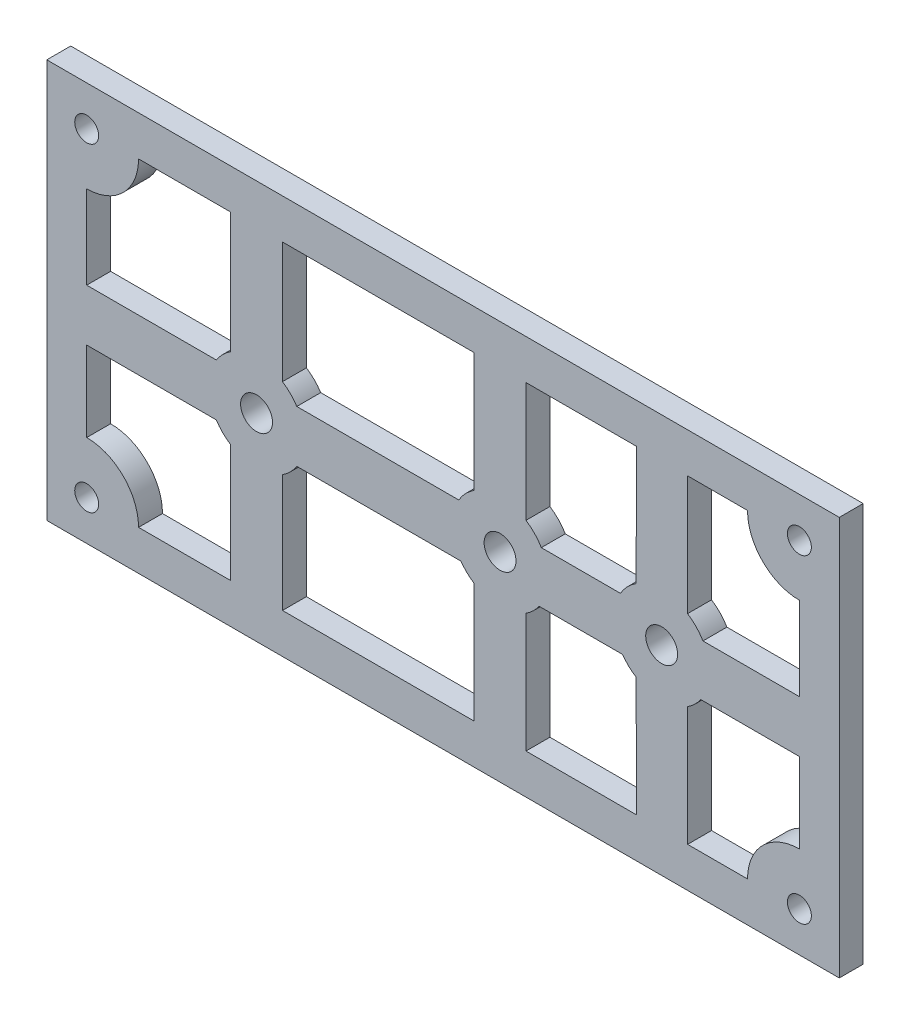
from build123d import *

# Parameters (mm, degrees)
SKETCH1_W               = 115
SKETCH1_H               = 50
BOSS_EXTRUDE1_DEPTH     = 3
CUT_EXTRUDE1_START      = -4
SKETCH2_R               = 1.5
CUT_EXTRUDE1_DEPTH      = 5
SKETCH4_R               = 2
CUT_EXTRUDE2_DEPTH      = 4
SKETCH5_R               = 2
CUT_EXTRUDE3_DEPTH      = 10
SKETCH6_R               = 2
CUT_EXTRUDE4_DEPTH      = 10
SKETCH7_W               = 15.674157042
SKETCH7_H               = 50
CUT_EXTRUDE5_DEPTH      = 10
MIRROR2_START           = -4
MIRROR2_COPY_1_SKETCH_R = 1.5
MIRROR2_COPY_1_DEPTH    = 5
CUT_EXTRUDE6_DEPTH      = 10


with BuildPart() as part:
    # Sketch1 → Boss-Extrude1 (new body)
    with BuildSketch(Plane.XY):
        Rectangle(SKETCH1_W, SKETCH1_H)
    extrude(amount=BOSS_EXTRUDE1_DEPTH)

    # Sketch2 → Cut-Extrude1 (cut)
    with BuildSketch(Plane.XY.offset(3).offset(CUT_EXTRUDE1_START)):
        with Locations((-52.5, 20)):
            Circle(SKETCH2_R)
    cut_extrude1 = extrude(amount=CUT_EXTRUDE1_DEPTH, mode=Mode.SUBTRACT)

    # Sketch4 → Cut-Extrude2 (cut, through all)
    with BuildSketch(Plane.XY.offset(3)):
        with Locations((-31.210457155, -0.20944607)):
            Circle(SKETCH4_R)
    extrude(amount=-CUT_EXTRUDE2_DEPTH, mode=Mode.SUBTRACT)

    # Sketch5 → Cut-Extrude3 (cut)
    with BuildSketch(Plane.XY.offset(3)):
        with Locations((-0.691956257, 0)):
            Circle(SKETCH5_R)
    extrude(amount=-CUT_EXTRUDE3_DEPTH, mode=Mode.SUBTRACT)

    # Sketch6 → Cut-Extrude4 (cut)
    with BuildSketch(Plane.XY.offset(3)):
        with Locations((19.565842958, 0)):
            Circle(SKETCH6_R)
    extrude(amount=-CUT_EXTRUDE4_DEPTH, mode=Mode.SUBTRACT)

    # Sketch7 → Cut-Extrude5 (cut)
    with BuildSketch(Plane.XY.offset(3)):
        with Locations((49.662921479, 0)):
            Rectangle(SKETCH7_W, SKETCH7_H)
    extrude(amount=-CUT_EXTRUDE5_DEPTH, mode=Mode.SUBTRACT)

    # Mirror1: Cut-Extrude1 across plane
    add(cut_extrude1.mirror(Plane.ZY.offset(7.837078521)), mode=Mode.SUBTRACT)

    # Mirror2: Cut-Extrude1 across plane
    add(cut_extrude1.mirror(Plane.ZX), mode=Mode.SUBTRACT)

    # Mirror2 copy 1 sketch → Mirror2 copy 1 (cut)
    with BuildSketch(Plane(origin=(-15.674157042, 0, 3), x_dir=(-1, 0, 0), z_dir=(0, 0, 1)).offset(MIRROR2_START)):
        with Locations((-52.5, 20)):
            Circle(MIRROR2_COPY_1_SKETCH_R)
    extrude(amount=MIRROR2_COPY_1_DEPTH, mode=Mode.SUBTRACT)

    # Sketch8 → Cut-Extrude6 (cut)
    with BuildSketch(Plane.XY.offset(3)):
        with BuildLine():
            ThreePointArc((-52.5, 13.5), (-47.903805922, 15.403805922), (-46, 20))
            Line((-46, 20), (-34.460457155, 20))
            Line((-34.460457155, 20), (-34.460457155, 4.834114181))
            ThreePointArc((-34.460457155, 4.834114181), (-35.453097842, 4.033194618), (-36.254017405, 3.04055393))
            Line((-36.254017405, 3.04055393), (-52.5, 3.04055393))
            Line((-52.5, 3.04055393), (-52.5, 13.5))
        make_face()
        with BuildLine():
            ThreePointArc((-3.941956257, 5.04356025), (-5.020668226, 4.15478672), (-5.864482893, 3.04055393))
            Line((-5.864482893, 3.04055393), (-26.166896904, 3.04055393))
            ThreePointArc((-26.166896904, 3.04055393), (-26.967816468, 4.033194618), (-27.960457155, 4.834114181))
            Line((-27.960457155, 4.834114181), (-27.960457155, 20))
            Line((-27.960457155, 20), (-3.941956257, 20))
            Line((-3.941956257, 20), (-3.941956257, 5.04356025))
        make_face()
        with BuildLine():
            ThreePointArc((4.480570379, 3.04055393), (3.636755712, 4.15478672), (2.558043743, 5.04356025))
            Line((2.558043743, 5.04356025), (2.558043743, 20))
            Line((2.558043743, 20), (16.44194335, 20))
            Line((16.44194335, 20), (16.347771528, 5.063992128))
            ThreePointArc((16.347771528, 5.063992128), (15.250277003, 4.168439815), (14.393316322, 3.04055393))
            Line((14.393316322, 3.04055393), (4.480570379, 3.04055393))
        make_face()
        with BuildLine():
            Line((36.825842958, 3.04055393), (36.825842958, 13.5))
            ThreePointArc((36.825842958, 13.5), (32.22964888, 15.403805922), (30.325842958, 20))
            Line((30.325842958, 20), (22.815842958, 20))
            Line((22.815842958, 20), (22.815842958, 5.04356025))
            ThreePointArc((22.815842958, 5.04356025), (23.894554927, 4.15478672), (24.738369593, 3.04055393))
            Line((24.738369593, 3.04055393), (36.825842958, 3.04055393))
        make_face()
        with BuildLine():
            Line((36.825842958, -13.5), (36.825842958, -3.45944607))
            Line((36.825842958, -3.45944607), (24.468111095, -3.45944607))
            ThreePointArc((24.468111095, -3.45944607), (23.718218589, -4.331024892), (22.815842958, -5.04356025))
            Line((22.815842958, -5.04356025), (22.815842958, -20))
            Line((22.815842958, -20), (30.325842958, -20))
            ThreePointArc((30.325842958, -20), (32.22964888, -15.403805922), (36.825842958, -13.5))
        make_face()
        with BuildLine():
            ThreePointArc((14.66357482, -3.45944607), (15.427169174, -4.344120085), (16.347771528, -5.063992128))
            Line((16.347771528, -5.063992128), (16.44194335, -20))
            Line((16.44194335, -20), (2.558043743, -20))
            Line((2.558043743, -20), (2.558043743, -5.04356025))
            ThreePointArc((2.558043743, -5.04356025), (3.460419374, -4.331024892), (4.21031188, -3.45944607))
            Line((4.21031188, -3.45944607), (14.66357482, -3.45944607))
        make_face()
        with BuildLine():
            ThreePointArc((-27.960457155, -5.25300632), (-26.967816468, -4.452086757), (-26.166896904, -3.45944607))
            Line((-26.166896904, -3.45944607), (-5.594224394, -3.45944607))
            ThreePointArc((-5.594224394, -3.45944607), (-4.844331888, -4.331024892), (-3.941956257, -5.04356025))
            Line((-3.941956257, -5.04356025), (-3.941956257, -20))
            Line((-3.941956257, -20), (-27.960457155, -20))
            Line((-27.960457155, -20), (-27.960457155, -5.25300632))
        make_face()
        with BuildLine():
            ThreePointArc((-36.254017405, -3.45944607), (-35.453097842, -4.452086757), (-34.460457155, -5.25300632))
            Line((-34.460457155, -5.25300632), (-34.460457155, -20))
            Line((-34.460457155, -20), (-46, -20))
            ThreePointArc((-46, -20), (-47.903805922, -15.403805922), (-52.5, -13.5))
            Line((-52.5, -13.5), (-52.5, -3.45944607))
            Line((-52.5, -3.45944607), (-36.254017405, -3.45944607))
        make_face()
    extrude(amount=-CUT_EXTRUDE6_DEPTH, mode=Mode.SUBTRACT)


solid = part.part
